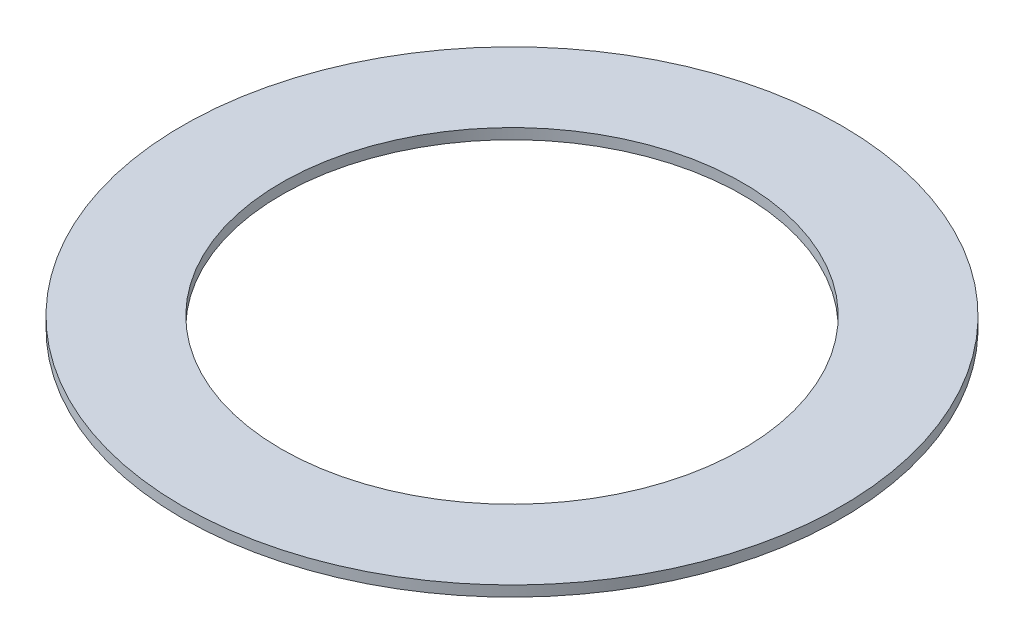
from build123d import *

# Parameters (mm, degrees)
SKETCH1_R           = 15.875
SKETCH1_R_2         = 11.1125
BOSS_EXTRUDE1_DEPTH = 0.508


with BuildPart() as part:
    # Sketch1 → Boss-Extrude1 (new body)
    with BuildSketch(Plane(origin=(0, 0, 0), x_dir=(1, 0, 0), z_dir=(0, 1, 0))):
        Circle(SKETCH1_R)
        Circle(SKETCH1_R_2, mode=Mode.SUBTRACT)
    extrude(amount=BOSS_EXTRUDE1_DEPTH)


solid = part.part
